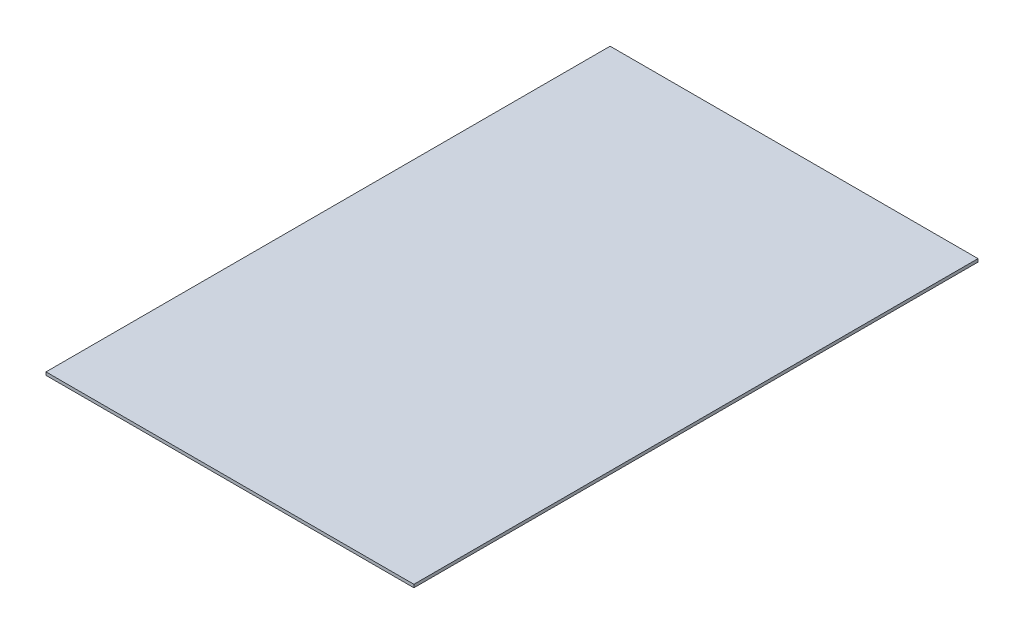
from build123d import *

# Parameters (mm, degrees)
SKETCH1_W           = 600
SKETCH1_H           = 920
BOSS_EXTRUDE1_DEPTH = 5


with BuildPart() as part:
    # Sketch1 → Boss-Extrude1 (new body)
    with BuildSketch(Plane(origin=(0, 0, 0), x_dir=(1, 0, 0), z_dir=(0, 1, 0))):
        with Locations((300, 460)):
            Rectangle(SKETCH1_W, SKETCH1_H)
    extrude(amount=BOSS_EXTRUDE1_DEPTH)


solid = part.part
